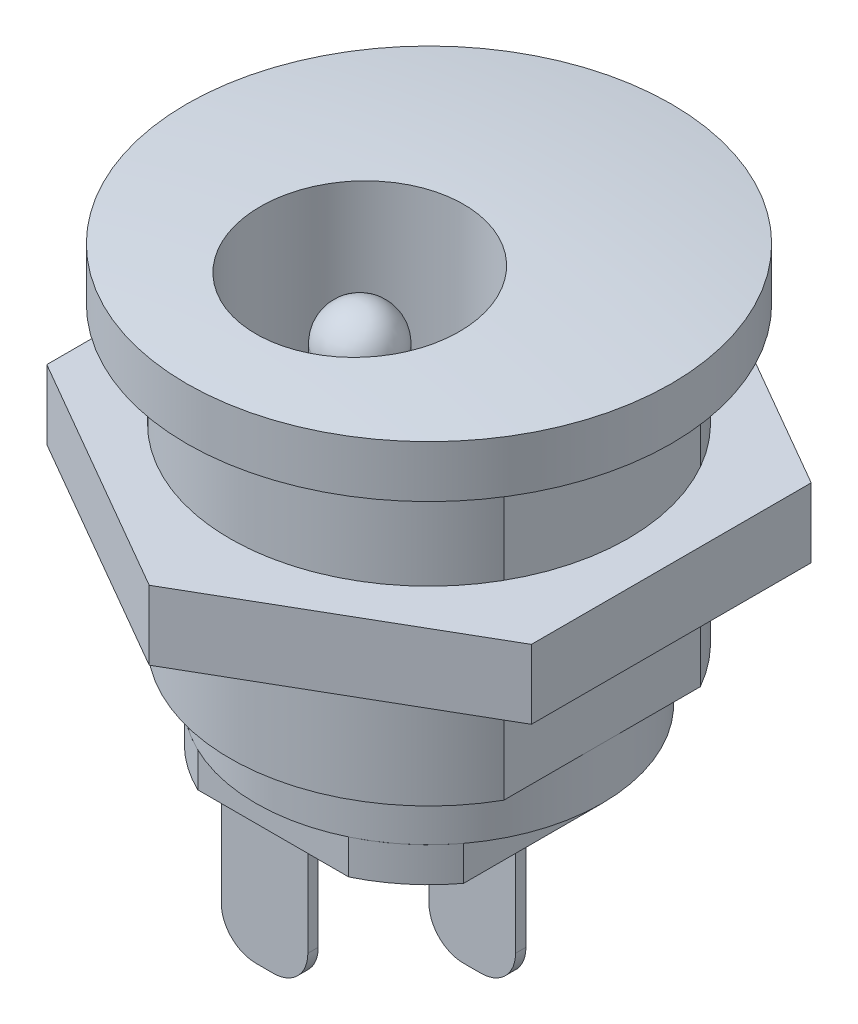
from build123d import *

# Parameters (mm, degrees)
SKETCH1_R               = 7
BOSS_EXTRUDE1_DEPTH     = 1.5
DOME1_FACE_RADIUS       = 7
DOME1_HEIGHT            = 0.5
SKETCH2_R               = 5.75
BOSS_EXTRUDE2_DEPTH     = 8.5
SKETCH3_R               = 5
BOSS_EXTRUDE3_DEPTH     = 1.5
CUT_EXTRUDE1_DEPTH      = 8.5
BOSS_EXTRUDE5_DEPTH     = 1
SKETCH6_R               = 3
CUT_EXTRUDE2_DEPTH      = 8
CUT_EXTRUDE2_DEPTH_BACK = 3
SKETCH7_R               = 1.05
BOSS_EXTRUDE6_DEPTH     = 8
DOME2_FACE_RADIUS       = 1.05
DOME2_HEIGHT            = 1.05
BOSS_EXTRUDE7_START     = 3
SKETCH8_R               = 5.75
BOSS_EXTRUDE7_DEPTH     = 2
SKETCH9_W               = 2.5
SKETCH9_H               = 0.3
SKETCH9_W_2             = 0.3
SKETCH9_H_2             = 2.5
BOSS_EXTRUDE8_DEPTH     = 4.5
FILLET1_R               = 1


with BuildPart() as part:
    # Sketch1 → Boss-Extrude1 (new body)
    with BuildSketch(Plane(origin=(0, 0, 0), x_dir=(1, 0, 0), z_dir=(0, 1, 0))):
        Circle(SKETCH1_R)
    extrude(amount=BOSS_EXTRUDE1_DEPTH)

    # Dome1: a dome of height H over a round flat face of radius A is a cap of a sphere of radius (A * A + H * H) / (2 * H)
    dome1_r = (DOME1_FACE_RADIUS * DOME1_FACE_RADIUS + DOME1_HEIGHT * DOME1_HEIGHT) / (2 * DOME1_HEIGHT)
    dome1_base = Plane((0, 1.5, 0), z_dir=(0, 1, 0))
    with Locations(dome1_base.offset(DOME1_HEIGHT - dome1_r)):
        dome1_ball = Sphere(dome1_r, mode=Mode.PRIVATE)
    add(split(dome1_ball, bisect_by=dome1_base, keep=Keep.TOP, mode=Mode.PRIVATE))

    # Sketch2 → Boss-Extrude2 (add)
    with BuildSketch(Plane.XZ):
        Circle(SKETCH2_R)
    extrude(amount=BOSS_EXTRUDE2_DEPTH)

    # Sketch3 → Boss-Extrude3 (add)
    with BuildSketch(Plane.XZ.offset(8.5)):
        Circle(SKETCH3_R)
    extrude(amount=BOSS_EXTRUDE3_DEPTH)

    # Sketch4 → Cut-Extrude1 (cut)
    with BuildSketch(Plane.XZ.offset(8.5)):
        with BuildLine():
            Line((-5, 2.839454173), (-5, -2.839454173))
            ThreePointArc((-5, -2.839454173), (-5.75, 0), (-5, 2.839454173))
        make_face()
        with BuildLine():
            Line((5, 2.839454173), (5, -2.839454173))
            ThreePointArc((5, -2.839454173), (5.75, 0), (5, 2.839454173))
        make_face()
    extrude(amount=-CUT_EXTRUDE1_DEPTH, mode=Mode.SUBTRACT)

    # Sketch6 → Cut-Extrude2 (cut, two sides)
    with BuildSketch(Plane.XZ) as cut_extrude2_sk:
        with Locations((0, 2)):
            Circle(SKETCH6_R)
    extrude(amount=CUT_EXTRUDE2_DEPTH, mode=Mode.SUBTRACT)
    extrude(cut_extrude2_sk.sketch, amount=-CUT_EXTRUDE2_DEPTH_BACK, mode=Mode.SUBTRACT)

    # Sketch7 → Boss-Extrude6 (add)
    with BuildSketch(Plane(origin=(0, -8, 0), x_dir=(1, 0, 0), z_dir=(0, 1, 0))):
        with Locations((0, -2)):
            Circle(SKETCH7_R)
    extrude(amount=BOSS_EXTRUDE6_DEPTH)

    # Dome2: a dome of height H over a round flat face of radius A is a cap of a sphere of radius (A * A + H * H) / (2 * H)
    dome2_r = (DOME2_FACE_RADIUS * DOME2_FACE_RADIUS + DOME2_HEIGHT * DOME2_HEIGHT) / (2 * DOME2_HEIGHT)
    dome2_base = Plane((0, 0, 2), z_dir=(0, 1, 0))
    with Locations(dome2_base.offset(DOME2_HEIGHT - dome2_r)):
        dome2_ball = Sphere(dome2_r, mode=Mode.PRIVATE)
    add(split(dome2_ball, bisect_by=dome2_base, keep=Keep.TOP, mode=Mode.PRIVATE))


with BuildPart() as body_2:
    # Sketch5 → Boss-Extrude5 (new body)
    with BuildSketch(Plane.XZ.offset(10)):
        with BuildLine():
            Line((-2.179449472, 4.5), (2.179449472, 4.5))
            ThreePointArc((2.179449472, 4.5), (3.179449472, 3.858898944), (4, 3))
            Line((4, 3), (4, -1))
            Line((4, -1), (2.5, -1))
            Line((2.5, -1), (2.5, -4.330127019))
            ThreePointArc((2.5, -4.330127019), (2.341265907, -4.417971701), (2.179449472, -4.5))
            Line((2.179449472, -4.5), (-2.179449472, -4.5))
            ThreePointArc((-2.179449472, -4.5), (-3.179449472, -3.858898944), (-4, -3))
            Line((-4, -3), (-4, 3))
            ThreePointArc((-4, 3), (-3.179449472, 3.858898944), (-2.179449472, 4.5))
        make_face()
    extrude(amount=BOSS_EXTRUDE5_DEPTH)

    # Sketch9 → Boss-Extrude8 (add)
    with BuildSketch(Plane.XZ.offset(11)):
        with Locations((-1.25, 3.35)):
            Rectangle(SKETCH9_W, SKETCH9_H)
        with Locations((1.75, 0.35)):
            Rectangle(SKETCH9_W, SKETCH9_H)
        with Locations((-3.35, -1.75)):
            Rectangle(SKETCH9_W_2, SKETCH9_H_2)
    extrude(amount=BOSS_EXTRUDE8_DEPTH)

    # Fillet1
    fillet1_edges = [body_2.edges().sort_by_distance(p)[0] for p in [
        (-2.5, -15.5, 3.35),
        (0, -15.5, 3.35),
        (0.5, -15.5, 0.35),
        (3, -15.5, 0.35),
        (-3.35, -15.5, -3),
        (-3.35, -15.5, -0.5),
    ]]
    fillet(fillet1_edges, radius=FILLET1_R)


with BuildPart() as body_3:
    # Sketch8 → Boss-Extrude7 (new body)
    with BuildSketch(Plane.XZ.offset(BOSS_EXTRUDE7_START)):
        Polygon((7, -4.041451884), (7, 4.041451884), (0, 8.082903769), (-7, 4.041451884), (-7, -4.041451884), (0, -8.082903769), align=None)
        Circle(SKETCH8_R, mode=Mode.SUBTRACT)
    extrude(amount=BOSS_EXTRUDE7_DEPTH)


solid = Compound([part.part, body_2.part, body_3.part])
